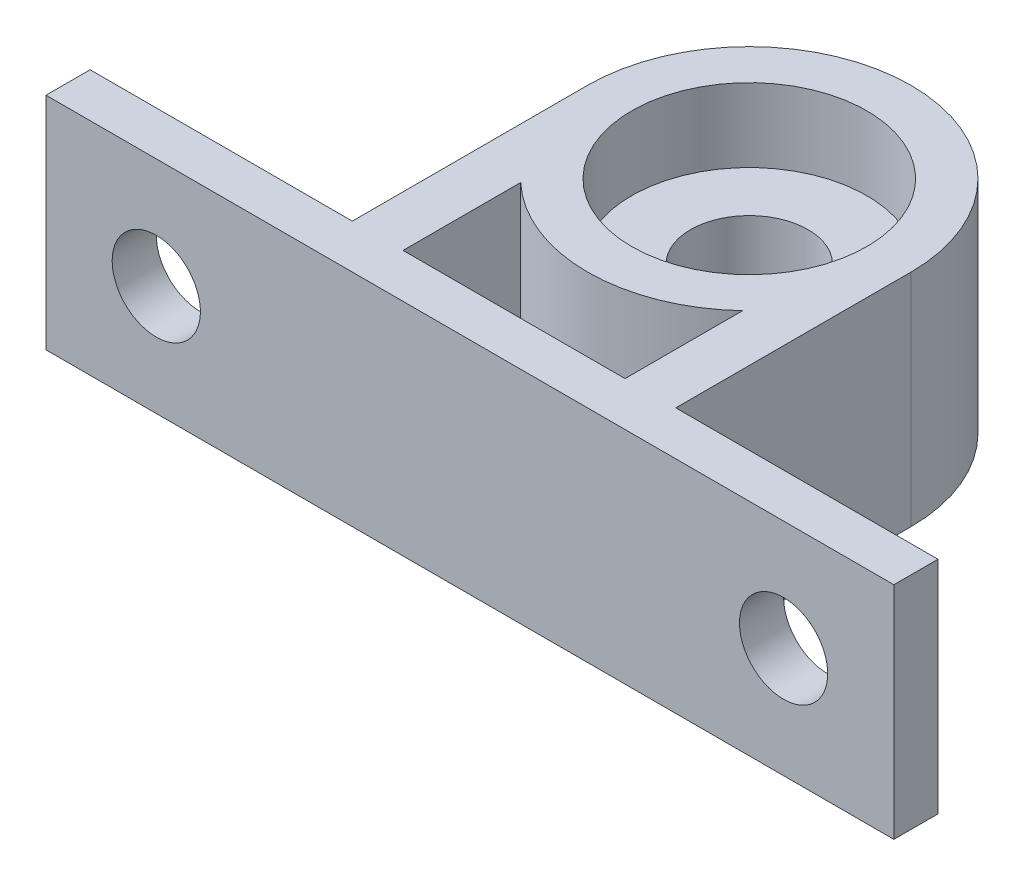
from build123d import *

# Parameters (mm, degrees)
SKETCH1_W           = 57.667844522
SKETCH1_H           = 30
BOSS_EXTRUDE1_DEPTH = 15
SKETCH2_R           = 4
CUT_EXTRUDE2_DEPTH  = 40
SKETCH3_R           = 8
CUT_EXTRUDE3_DEPTH  = 5
CUT_EXTRUDE5_DEPTH  = 16
SKETCH5_R           = 3
CUT_EXTRUDE6_DEPTH  = 5


with BuildPart() as part:
    # Sketch1 → Boss-Extrude1 (new body)
    with BuildSketch(Plane(origin=(0, 0, 0), x_dir=(1, 0, 0), z_dir=(0, 1, 0))):
        Rectangle(SKETCH1_W, SKETCH1_H)
    extrude(amount=BOSS_EXTRUDE1_DEPTH)

    # Sketch2 → Cut-Extrude2 (cut)
    with BuildSketch(Plane(origin=(0, 15, 0), x_dir=(1, 0, 0), z_dir=(0, 1, 0))):
        with Locations((0, 4)):
            Circle(SKETCH2_R)
    extrude(amount=-CUT_EXTRUDE2_DEPTH, mode=Mode.SUBTRACT)

    # Sketch3 → Cut-Extrude3 (cut)
    with BuildSketch(Plane(origin=(0, 15, 0), x_dir=(1, 0, 0), z_dir=(0, 1, 0))):
        with Locations((0, 4)):
            Circle(SKETCH3_R)
    extrude(amount=-CUT_EXTRUDE3_DEPTH, mode=Mode.SUBTRACT)

    # Sketch4 → Cut-Extrude5 (cut, through all)
    with BuildSketch(Plane(origin=(0, 15, 0), x_dir=(1, 0, 0), z_dir=(0, 1, 0))):
        with BuildLine():
            ThreePointArc((-11, 4), (-7.778174609, 11.778174577), (-4.5e-08, 15))
            Line((-4.5e-08, 15), (-28.833922261, 15))
            Line((-28.833922261, 15), (-28.833922261, -12))
            Line((-28.833922261, -12), (-11, -12))
            Line((-11, -12), (-11, 4))
        make_face()
        with BuildLine():
            ThreePointArc((-4.5e-08, 15), (7.778174577, 11.778174609), (11, 4))
            Line((11, 4), (11, -12))
            Line((11, -12), (28.833922261, -12))
            Line((28.833922261, -12), (28.833922261, 15))
            Line((28.833922261, 15), (-4.5e-08, 15))
        make_face()
        with BuildLine():
            Line((7.549834435, -12), (7.549834435, -4))
            ThreePointArc((7.549834435, -4), (0, -7), (-7.549834435, -4))
            Line((-7.549834435, -4), (-7.549834435, -12))
            Line((-7.549834435, -12), (7.549834435, -12))
        make_face()
    extrude(amount=-CUT_EXTRUDE5_DEPTH, mode=Mode.SUBTRACT)

    # Sketch5 → Cut-Extrude6 (cut)
    with BuildSketch(Plane(origin=(0, 0, 12), x_dir=(-1, 0, 0), z_dir=(0, 0, -1))):
        with Locations((21.333922261, 7.5)):
            Circle(SKETCH5_R)
        with Locations((-21.333922261, 7.5)):
            Circle(SKETCH5_R)
    extrude(amount=-CUT_EXTRUDE6_DEPTH, mode=Mode.SUBTRACT)


solid = part.part
